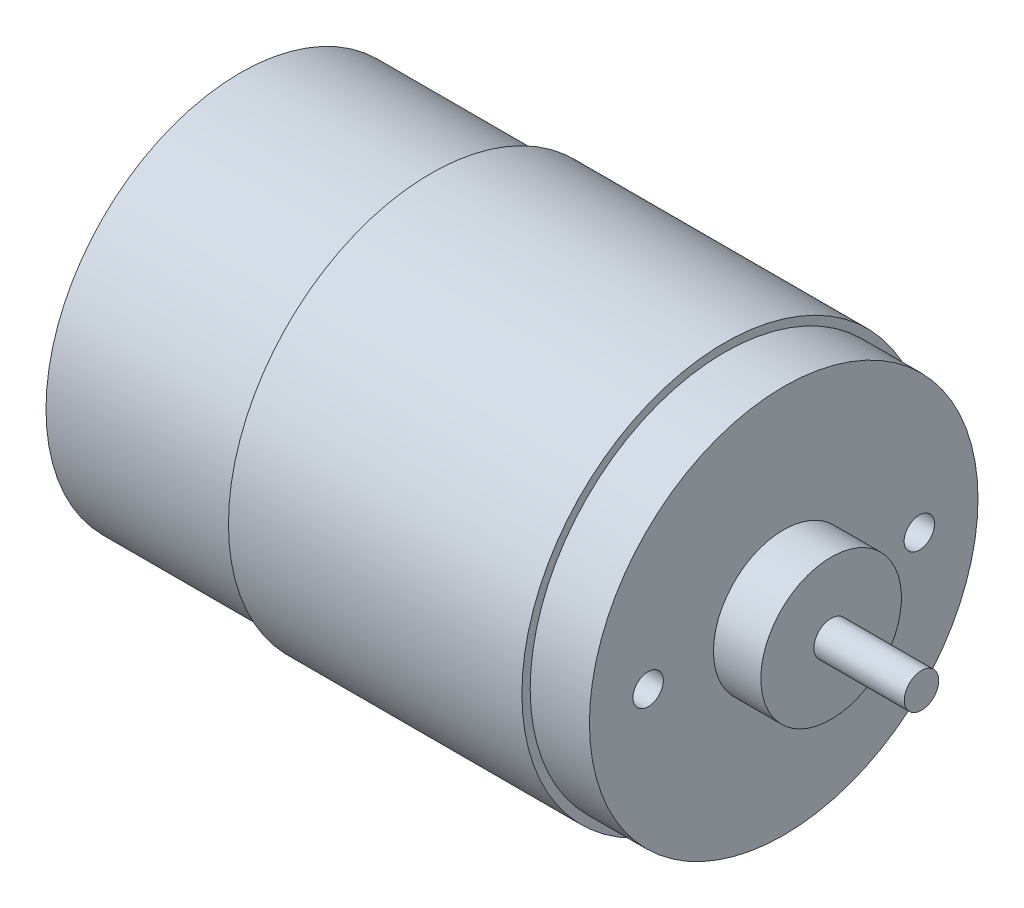
from build123d import *

# Parameters (mm, degrees)
SKETCH2_R          = 1.4
CUT_EXTRUDE1_DEPTH = 6.35


with BuildPart() as part:
    # Sketch1 → Revolve1 (revolve)
    with BuildSketch(Plane.XY):
        Polygon((-29.804083682, 0), (-29.804083682, 1.534627615), (-28.915615063, 1.534627615), (-28.915615063, 2.665405858), (-27.623297071, 2.665405858), (-27.623297071, 4.765422594), (-26.694443515, 5.694276151), (-24.647883682, 5.694276151), (-24.647883682, 17.907), (-7.071083682, 17.907), (-7.071083682, 18.669), (19.979916318, 18.669), (19.979916318, 17.907), (25.440916318, 17.907), (25.440916318, 6.477), (29.809716318, 6.477), (29.809716318, 1.5875), (38.140916318, 1.5875), (38.140916318, 0), align=None)
    revolve(axis=Axis((-37.638761506, 0, 0), (1, 0, 0)))

    # Sketch2 → Cut-Extrude1 (cut)
    with BuildSketch(Plane(origin=(25.440916318, 0, 0), x_dir=(0, 0, -1), z_dir=(1, 0, 0))):
        with Locations((-12.4968, 0)):
            Circle(SKETCH2_R)
        with Locations((12.4968, 0)):
            Circle(SKETCH2_R)
    extrude(amount=-CUT_EXTRUDE1_DEPTH, mode=Mode.SUBTRACT)


solid = part.part
